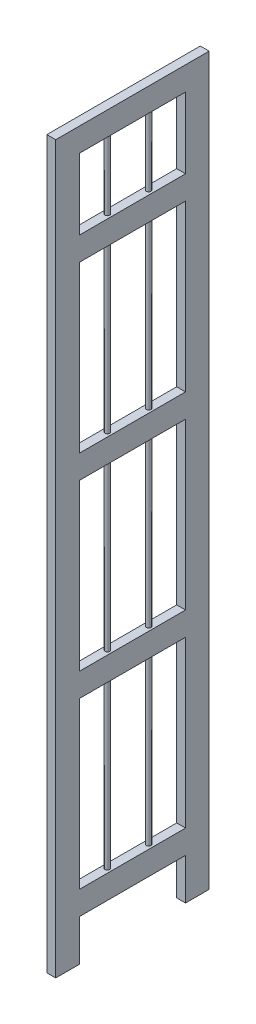
from build123d import *

# Parameters (mm, degrees)
EXTRUDE_1_DEPTH        = 15
SKETCH_2_W             = 180
SKETCH_2_H             = 40
EXTRUDE_2_DEPTH        = 15
PATTERN_LINEAR_1_COUNT = 4
PATTERN_LINEAR_1_PITCH = 320
SKETCH_3_R             = 4
EXTRUDE_3_DEPTH        = 1080


with BuildPart() as part:
    # 草图1 → 凸台-拉伸1 (new body)
    with BuildSketch(Plane(origin=(0, 0, 0), x_dir=(0, 0, -1), z_dir=(1, 0, 0))):
        Polygon((-90, 0), (-90, 1190), (90, 1190), (90, 0), (130, 0), (130, 1230), (-130, 1230), (-130, 0), align=None)
    extrude(amount=-EXTRUDE_1_DEPTH)

    # 草图2 → 凸台-拉伸2 (add)
    with BuildSketch(Plane(origin=(0, 0, 0), x_dir=(0, 0, -1), z_dir=(1, 0, 0))):
        with Locations((0, 90)):
            Rectangle(SKETCH_2_W, SKETCH_2_H)
    extrude_2 = extrude(amount=-EXTRUDE_2_DEPTH)

    # 阵列(线性)1: 凸台-拉伸2 ×4
    with Locations(*[(0, i * PATTERN_LINEAR_1_PITCH, 0) for i in range(1, PATTERN_LINEAR_1_COUNT)]):
        add(extrude_2)

    # 草图3 → 凸台-拉伸3 (add)
    with BuildSketch(Plane(origin=(0, 110, 0), x_dir=(1, 0, 0), z_dir=(0, 1, 0))):
        with Locations((-7.5, -35)):
            Circle(SKETCH_3_R)
    extrude_3 = extrude(amount=EXTRUDE_3_DEPTH)

    # 镜向1: 凸台-拉伸3 across plane
    add(extrude_3.mirror(Plane.XY))


solid = part.part
